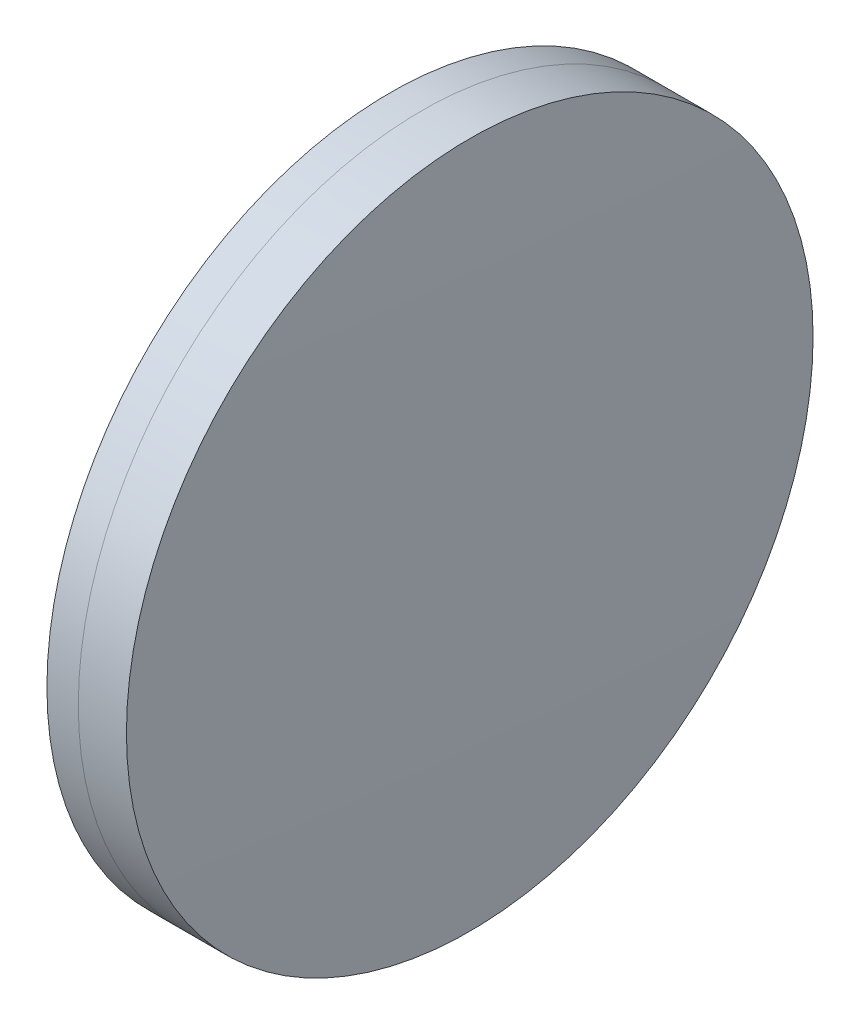
from build123d import *


with BuildPart() as part:
    # 草图1 one side → 旋转1 (revolve)
    with BuildSketch(Plane(origin=(0, 0, 0), x_dir=(1, 0, 0), z_dir=(0, 1, 0)), mode=Mode.PRIVATE) as revolve_1_sk:
        with BuildLine():
            ThreePointArc((713.612240888, 25.4), (712.913557971, 12.708540737), (712.680559274, 0))
            Line((712.680559274, 0), (717.180559274, 0))
            ThreePointArc((717.180559274, 0), (716.868732535, 12.715285142), (715.934002017, 25.4))
            Line((715.934002017, 25.4), (713.612240888, 25.4))
        make_face()
    revolve(revolve_1_sk.sketch.rotate(Axis((124.523309526, 0, 0), (1, 0, 0)), 180), axis=Axis((124.523309526, 0, 0), (1, 0, 0)))  # turned: the seam where the file's is


with BuildPart() as body_2:
    # 草图2 one side → 旋转3 (revolve)
    with BuildSketch(Plane(origin=(0, 0, 0), x_dir=(1, 0, 0), z_dir=(0, 1, 0)), mode=Mode.PRIVATE) as revolve_3_sk:
        with BuildLine():
            Line((719.49565943, 25.4), (715.934002017, 25.4))
            ThreePointArc((715.934002017, 25.4), (716.868732535, 12.715285142), (717.180559274, 0))
            Line((717.180559274, 0), (719.780559274, 0))
            ThreePointArc((719.780559274, 0), (719.709332073, 12.700798872), (719.49565943, 25.4))
        make_face()
    revolve(revolve_3_sk.sketch.rotate(Axis((-0.551919993, 0, 0), (1, 0, 0)), 180), axis=Axis((-0.551919993, 0, 0), (1, 0, 0)))  # turned: the seam where the file's is


solid = Compound([part.part, body_2.part])
